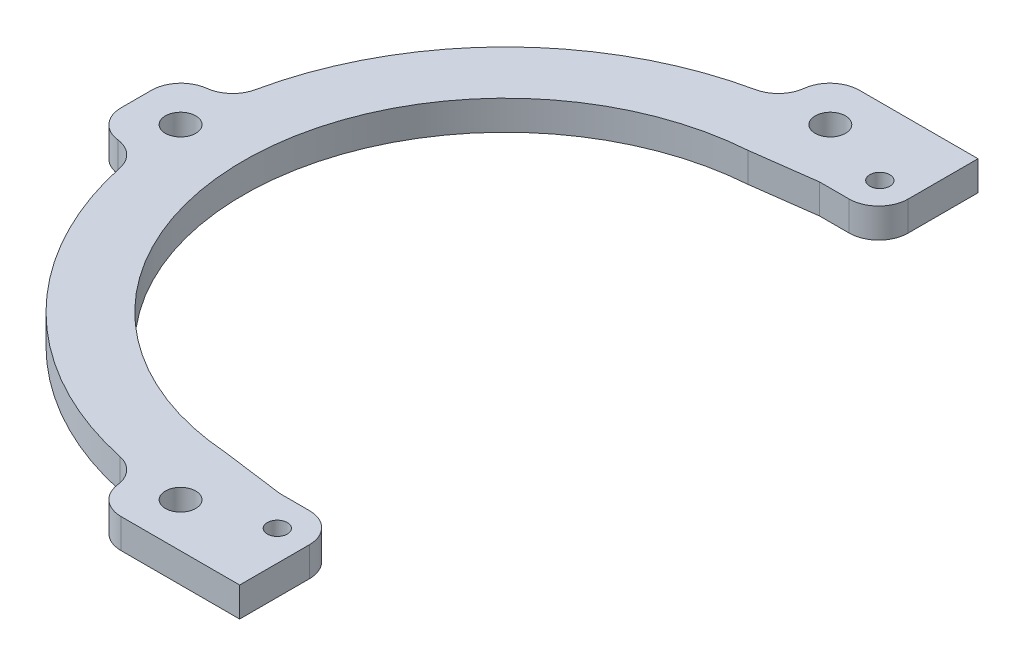
from build123d import *

# Parameters (mm, degrees)
SKETCH1_R                = 69.85
SKETCH1_R_2              = 56.35625
BOSS_EXTRUDE1_DEPTH      = 6.35
SKETCH5_W                = 19.05
SKETCH5_H                = 15.875
BOSS_EXTRUDE2_DEPTH      = 6.35
FILLET1_R                = 6.35
CIRPATTERN2_COUNT        = 3
CIRPATTERN2_ANGLE        = 180
FILLET1_OF_CIRPATTERN2_R = 6.35
SKETCH11_R               = 3.2639
CUT_EXTRUDE2_DEPTH       = 113.432663181
CIRPATTERN3_COUNT        = 3
CIRPATTERN3_ANGLE        = 180
CUT_EXTRUDE4_DEPTH       = 113.432663181
FILLET8_R                = 6.35
SKETCH22_W               = 21.356989326
SKETCH22_H               = 6.35
BOSS_EXTRUDE3_DEPTH      = 12.7
SKETCH23_R               = 2.15265
CUT_EXTRUDE5_DEPTH       = 113.432663328
FILLET11_R               = 6.35


with BuildPart() as part:
    # Sketch1 → Boss-Extrude1 (new body)
    with BuildSketch(Plane(origin=(0, 0, 0), x_dir=(1, 0, 0), z_dir=(0, 1, 0))):
        with Locations(Location((0, 0, 0), (0, 0, 270))):
            Circle(SKETCH1_R)
        with Locations(Location((0, 0, 0), (0, 0, 270))):
            Circle(SKETCH1_R_2, mode=Mode.SUBTRACT)
    extrude(amount=BOSS_EXTRUDE1_DEPTH)

    # Sketch5 → Boss-Extrude2 (add)
    with BuildSketch(Plane(origin=(0, 6.35, 0), x_dir=(1, 0, 0), z_dir=(0, 1, 0))):
        with Locations((0, 71.4375)):
            Rectangle(SKETCH5_W, SKETCH5_H)
    boss_extrude2 = extrude(amount=-BOSS_EXTRUDE2_DEPTH)

    # Fillet1
    fillet1_edges = [part.edges().sort_by_distance(p)[0] for p in [
        (9.525, 3.175, -69.197520729),
        (-9.525, 3.175, -69.197520729),
    ]]
    fillet(fillet1_edges, radius=FILLET1_R)

    # CirPattern2: Boss-Extrude2 ×3 about axis
    cirpattern2_axis = Axis((0, 0, 0), (0, 1, 0))
    for i in range(1, CIRPATTERN2_COUNT):
        add(boss_extrude2.rotate(cirpattern2_axis, i * CIRPATTERN2_ANGLE / (CIRPATTERN2_COUNT - 1)))

    # Fillet1 of CirPattern2
    fillet1_of_cirpattern2_edges = [part.edges().sort_by_distance(p)[0] for p in [
        (-69.197520729, 3.175, -9.525),
        (-69.197520729, 3.175, 9.525),
        (-9.525, 3.175, 69.197520729),
        (9.525, 3.175, 69.197520729),
    ]]
    fillet(fillet1_of_cirpattern2_edges, radius=FILLET1_OF_CIRPATTERN2_R)

    # Sketch11 → Cut-Extrude2 (cut, through all)
    with BuildSketch(Plane.XZ):
        with Locations(Location((0, -69.85, 0), (0, 0, 270))):
            Circle(SKETCH11_R)
    cut_extrude2 = extrude(amount=-CUT_EXTRUDE2_DEPTH, mode=Mode.SUBTRACT)

    # CirPattern3: Cut-Extrude2 ×3 about axis
    cirpattern3_axis = Axis((0, 0, 0), (0, 1, 0))
    for i in range(1, CIRPATTERN3_COUNT):
        add(cut_extrude2.rotate(cirpattern3_axis, i * CIRPATTERN3_ANGLE / (CIRPATTERN3_COUNT - 1)), mode=Mode.SUBTRACT)

    # Sketch14 → Cut-Extrude4 (cut, through all)
    with BuildSketch(Plane(origin=(0, 6.35, 0), x_dir=(1, 0, 0), z_dir=(0, 1, 0))):
        Polygon((76.141203704, 74.528010674), (76.141203704, -74.528010674), (9.525, -74.528010674), (9.525, -58.018010674), (-10.795, -55.312700974), (-10.795, 55.312700974), (9.525, 58.018010674), (9.525, 74.528010674), align=None)
    extrude(amount=-CUT_EXTRUDE4_DEPTH, mode=Mode.SUBTRACT)

    # Fillet8
    fillet8_edges = [part.edges().sort_by_distance(p)[0] for p in [
        (-9.525, 3.175, 79.375),
        (-79.375, 3.175, 9.525),
        (-79.375, 3.175, -9.525),
        (-9.525, 3.175, -79.375),
    ]]
    fillet(fillet8_edges, radius=FILLET8_R)

    # Sketch22 → Boss-Extrude3 (add)
    with BuildSketch(Plane(origin=(9.525, 0, 0), x_dir=(0, 0, -1), z_dir=(1, 0, 0))):
        with Locations((68.696505337, 3.175)):
            Rectangle(SKETCH22_W, SKETCH22_H)
    boss_extrude3 = extrude(amount=BOSS_EXTRUDE3_DEPTH)

    # Sketch23 → Cut-Extrude5 (cut, through all)
    with BuildSketch(Plane(origin=(0, 6.35, 0), x_dir=(1, 0, 0), z_dir=(0, 1, 0))):
        with Locations(Location((15.7226, 64.77, 0), (0, 0, 270))):
            Circle(SKETCH23_R)
    cut_extrude5 = extrude(amount=-CUT_EXTRUDE5_DEPTH, mode=Mode.SUBTRACT)

    # Mirror1: Boss-Extrude3, Cut-Extrude5 across plane
    add(boss_extrude3.mirror(Plane.XY))
    add(cut_extrude5.mirror(Plane.XY), mode=Mode.SUBTRACT)

    # Fillet11
    fillet11_edges = [part.edges().sort_by_distance(p)[0] for p in [
        (22.225, 3.175, -58.018010674),
        (22.225, 3.175, 58.018010674),
    ]]
    fillet(fillet11_edges, radius=FILLET11_R)


solid = part.part
